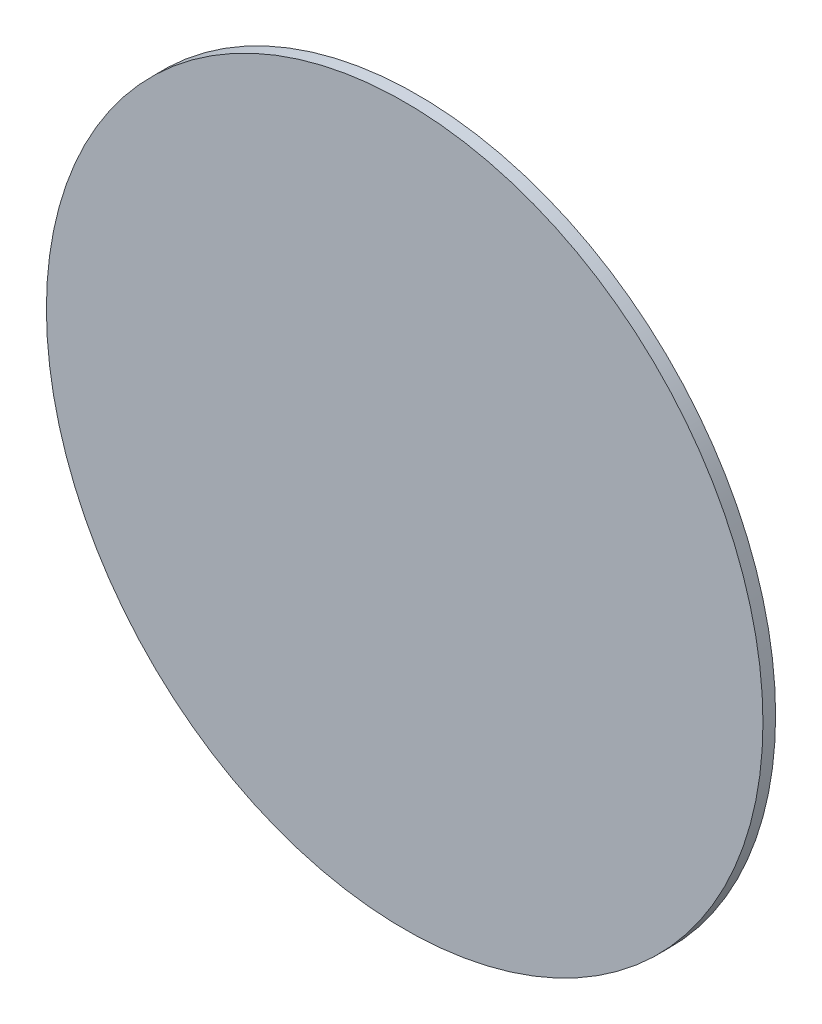
from build123d import *

# Parameters (mm, degrees)
SKETCH1_R           = 85
BOSS_EXTRUDE1_DEPTH = 3


with BuildPart() as part:
    # Sketch1 → Boss-Extrude1 (new body)
    with BuildSketch(Plane.XY):
        Circle(SKETCH1_R)
    extrude(amount=BOSS_EXTRUDE1_DEPTH)


solid = part.part
